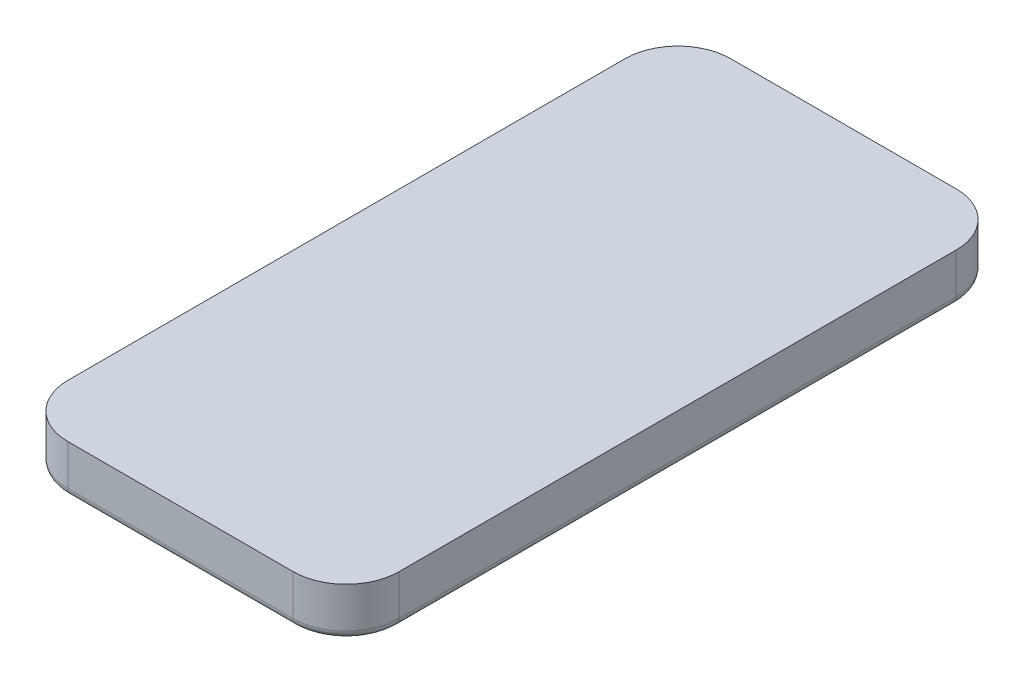
from build123d import *

# Parameters (mm, degrees)
SKETCH_1_W      = 75.1
SKETCH_1_H      = 150.3
EXTRUDE_1_DEPTH = 11
FILLET_1_R      = 12
FILLET_2_R      = 1.8
EXTRUDE_2_DEPTH = 2.5


with BuildPart() as part:
    # 草图1 → 凸台-拉伸1 (new body)
    with BuildSketch(Plane(origin=(0, 0, 0), x_dir=(1, 0, 0), z_dir=(0, 1, 0))):
        Rectangle(SKETCH_1_W, SKETCH_1_H)
    extrude(amount=EXTRUDE_1_DEPTH)

    # 圆角1
    fillet_1_edges = [part.edges().sort_by_distance(p)[0] for p in [
        (37.55, 5.5, 75.15),
        (-37.55, 5.5, 75.15),
        (-37.55, 5.5, -75.15),
        (37.55, 5.5, -75.15),
    ]]
    fillet(fillet_1_edges, radius=FILLET_1_R)

    # 圆角2
    fillet_2_edges = [part.edges().sort_by_distance(p)[0] for p in [
        (0, 0, -75.15),
        (37.55, 0, 0),
        (0, 0, 75.15),
        (-37.55, 0, 0),
        (-34.035281374, 0, -71.635281374),
        (-34.035281374, 0, 71.635281374),
        (34.035281374, 0, 71.635281374),
        (34.035281374, 0, -71.635281374),
    ]]
    fillet(fillet_2_edges, radius=FILLET_2_R)

    # 草图2 → 凸台-拉伸2 (add)
    with BuildSketch(Plane.XZ):
        with BuildLine():
            Line((21.45, -29.85), (5.45, -29.85))
            ThreePointArc((5.45, -29.85), (-3.035281374, -33.364718626), (-6.55, -41.85))
            Line((-6.55, -41.85), (-6.55, -58.65))
            ThreePointArc((-6.55, -58.65), (-3.035281374, -67.135281374), (5.45, -70.65))
            Line((5.45, -70.65), (21.45, -70.65))
            ThreePointArc((21.45, -70.65), (29.935281374, -67.135281374), (33.45, -58.65))
            Line((33.45, -58.65), (33.45, -41.85))
            ThreePointArc((33.45, -41.85), (29.935281374, -33.364718626), (21.45, -29.85))
        make_face()
    extrude(amount=EXTRUDE_2_DEPTH)


solid = part.part
